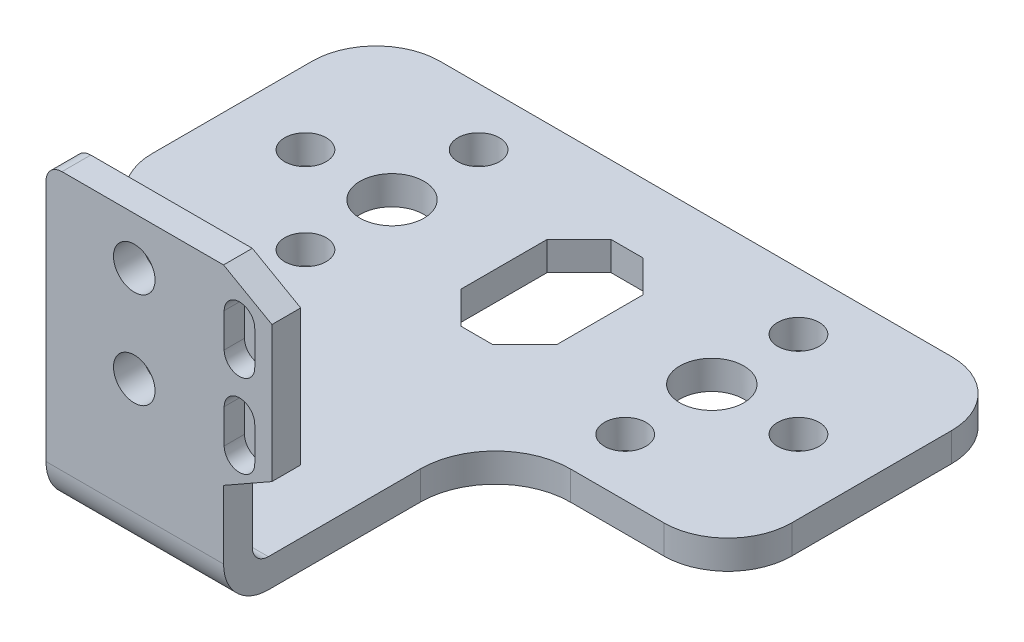
from build123d import *

# Parameters (mm, degrees)
BOSS_EXTRUDE1_DEPTH      = 50
SKETCH2_OUTSIDE_W        = 130.372
SKETCH2_OUTSIDE_H        = 120.372
SKETCH2_OUTSIDE_R        = 5
SKETCH2_OUTSIDE_R_2      = 3.25
CUT_EXTRUDE34_DEPTH      = 46
CUT_EXTRUDE34_DEPTH_BACK = 1
BOSS_EXTRUDE3_DEPTH      = 4.5
FILLET3_R                = 2.5
FILLET4_R                = 7
SKETCH6_R                = 3.25
CUT_EXTRUDE35_DEPTH      = 1
CUT_EXTRUDE35_DEPTH_BACK = 88.5
CUT_EXTRUDE39_DEPTH      = 3.18


with BuildPart() as part:
    # Sketch1 → Boss-Extrude1 (new body, symmetric)
    with BuildSketch(Plane(origin=(0, 0, 0), x_dir=(0, 0, -1), z_dir=(1, 0, 0))):
        Polygon((0, 0), (0, 45), (4.5, 45), (4.5, 4.5), (90, 4.5), (90, 0), align=None)
    extrude(amount=BOSS_EXTRUDE1_DEPTH, both=True)

    # Sketch2 outside → Cut-Extrude34 (cut, two sides)
    with BuildSketch(Plane(origin=(0, 0, 0), x_dir=(1, 0, 0), z_dir=(0, 1, 0))) as cut_extrude34_sk:
        with Locations((0, 45)):
            Rectangle(SKETCH2_OUTSIDE_W, SKETCH2_OUTSIDE_H)
        with BuildLine():
            Line((-40, 45), (-25.836010131, 45))
            ThreePointArc((-25.836010131, 45), (-17.535836731, 41.561955607), (-14.097792338, 33.261782207))
            Line((-14.097792338, 33.261782207), (-14.097792338, 7))
            Line((-14.097792338, 7), (13.661782207, 7))
            Line((13.661782207, 7), (13.661782207, 33.261782207))
            ThreePointArc((13.661782207, 33.261782207), (17.099826599, 41.561955607), (25.4, 45))
            Line((25.4, 45), (40, 45))
            ThreePointArc((40, 45), (47.071067812, 47.928932188), (50, 55))
            Line((50, 55), (50, 80))
            ThreePointArc((50, 80), (47.071067812, 87.071067812), (40, 90))
            Line((40, 90), (-40, 90))
            ThreePointArc((-40, 90), (-47.071067812, 87.071067812), (-50, 80))
            Line((-50, 80), (-50, 55))
            ThreePointArc((-50, 55), (-47.071067812, 47.928932188), (-40, 45))
        make_face(mode=Mode.SUBTRACT)
        with Locations((-25, 67.5)):
            Circle(SKETCH2_OUTSIDE_R)
        with Locations((25, 67.5)):
            Circle(SKETCH2_OUTSIDE_R)
        with Locations((25, 81.04)):
            Circle(SKETCH2_OUTSIDE_R_2)
        with Locations((25, 53.96)):
            Circle(SKETCH2_OUTSIDE_R_2)
        with Locations((38.54, 67.5)):
            Circle(SKETCH2_OUTSIDE_R_2)
        with Locations((-25, 81.04)):
            Circle(SKETCH2_OUTSIDE_R_2)
        with Locations((-25, 53.96)):
            Circle(SKETCH2_OUTSIDE_R_2)
        with Locations((-38.54, 67.5)):
            Circle(SKETCH2_OUTSIDE_R_2)
        Polygon((-2.5, 79.24), (2.5, 79.24), (7.5, 74.24), (7.5, 60.76), (2.5, 55.76), (-2.5, 55.76), (-7.5, 60.76), (-7.5, 74.24), align=None)
    extrude(amount=CUT_EXTRUDE34_DEPTH, mode=Mode.SUBTRACT)
    extrude(cut_extrude34_sk.sketch, amount=-CUT_EXTRUDE34_DEPTH_BACK, mode=Mode.SUBTRACT)

    # Sketch4 → Boss-Extrude3 (add)
    with BuildSketch(Plane.XY.offset(-7)):
        with BuildLine():
            Line((-14.097792338, 0), (-14.097792338, 45))
            ThreePointArc((-14.097792338, 45), (-13.365559291, 46.767766953), (-11.597792338, 47.5))
            Line((-11.597792338, 47.5), (13.661782207, 47.5))
            Line((13.661782207, 47.5), (21.222778521, 43.209368433))
            Line((21.222778521, 43.209368433), (21.222778521, 21.944029683))
            Line((21.222778521, 21.944029683), (13.661782207, 17.653398116))
            Line((13.661782207, 17.653398116), (13.661782207, 4.5))
            Line((13.661782207, 4.5), (13.661782207, 0))
            Line((13.661782207, 0), (-14.097792338, 0))
        make_face()
    extrude(amount=BOSS_EXTRUDE3_DEPTH)

    # Fillet3
    fillet3_edges = [part.edges().sort_by_distance(p)[0] for p in [
        (-0.218005066, 4.5, -7),
    ]]
    fillet(fillet3_edges, radius=FILLET3_R)

    # Fillet4
    fillet4_edges = [part.edges().sort_by_distance(p)[0] for p in [
        (-0.218005066, 0, -2.5),
    ]]
    fillet(fillet4_edges, radius=FILLET4_R)

    # Sketch6 → Cut-Extrude35 (cut, two sides)
    with BuildSketch(Plane.XY.offset(-2.5)) as cut_extrude35_sk:
        with Locations((-0.297792338, 40.083077312)):
            Circle(SKETCH6_R)
        with Locations((-0.297792338, 25.083077312)):
            Circle(SKETCH6_R)
    extrude(amount=CUT_EXTRUDE35_DEPTH, mode=Mode.SUBTRACT)
    extrude(cut_extrude35_sk.sketch, amount=-CUT_EXTRUDE35_DEPTH_BACK, mode=Mode.SUBTRACT)

    # Sketch7 → Cut-Extrude39 (cut)
    with BuildSketch(Plane.XY.offset(-2.5)):
        with BuildLine():
            Line((18.539617084, 41.355633115), (18.539617084, 36.032215871))
            ThreePointArc((18.539617084, 36.032215871), (16.149617084, 33.642215871), (13.759617084, 36.032215871))
            Line((13.759617084, 36.032215871), (13.759617084, 41.355633115))
            ThreePointArc((13.759617084, 41.355633115), (16.149617084, 43.745633115), (18.539617084, 41.355633115))
        make_face()
        with BuildLine():
            Line((18.539617084, 28.355633115), (18.539617084, 23.032215871))
            ThreePointArc((18.539617084, 23.032215871), (16.149617084, 20.642215871), (13.759617084, 23.032215871))
            Line((13.759617084, 23.032215871), (13.759617084, 28.355633115))
            ThreePointArc((13.759617084, 28.355633115), (16.149617084, 30.745633115), (18.539617084, 28.355633115))
        make_face()
    extrude(amount=-CUT_EXTRUDE39_DEPTH, mode=Mode.SUBTRACT)


solid = part.part
